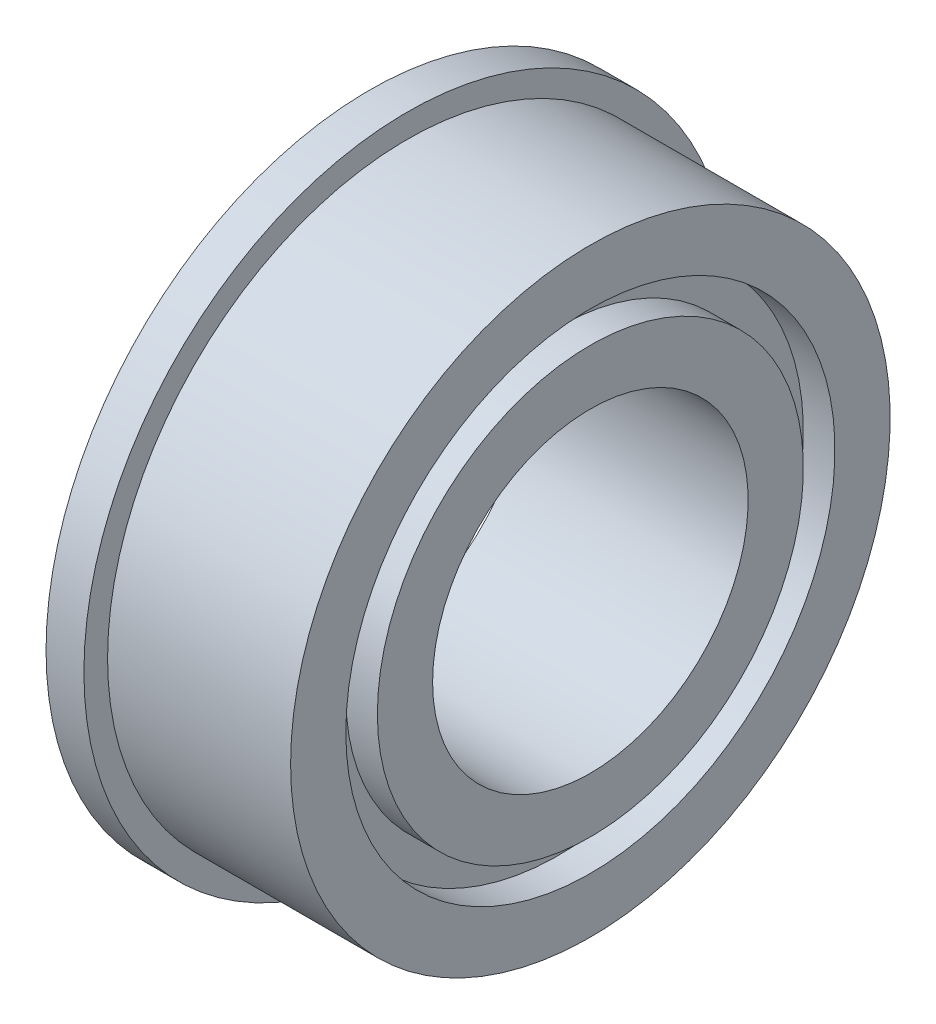
from build123d import *


with BuildPart() as part:
    # Sketch2 → Revolve1 (revolve)
    with BuildSketch(Plane.XY):
        Polygon((-1.2, 10.25), (0, 10.25), (0, 9.5), (5.8, 9.5), (5.8, 7.75), (4.8, 7.75), (4.8, 6.75), (5.8, 6.75), (5.8, 5), (-1.2, 5), (-1.2, 6.75), (-0.2, 6.75), (-0.2, 7.75), (-1.2, 7.75), align=None)
    revolve(axis=Axis((0, 0, 0), (1, 0, 0)))


solid = part.part
